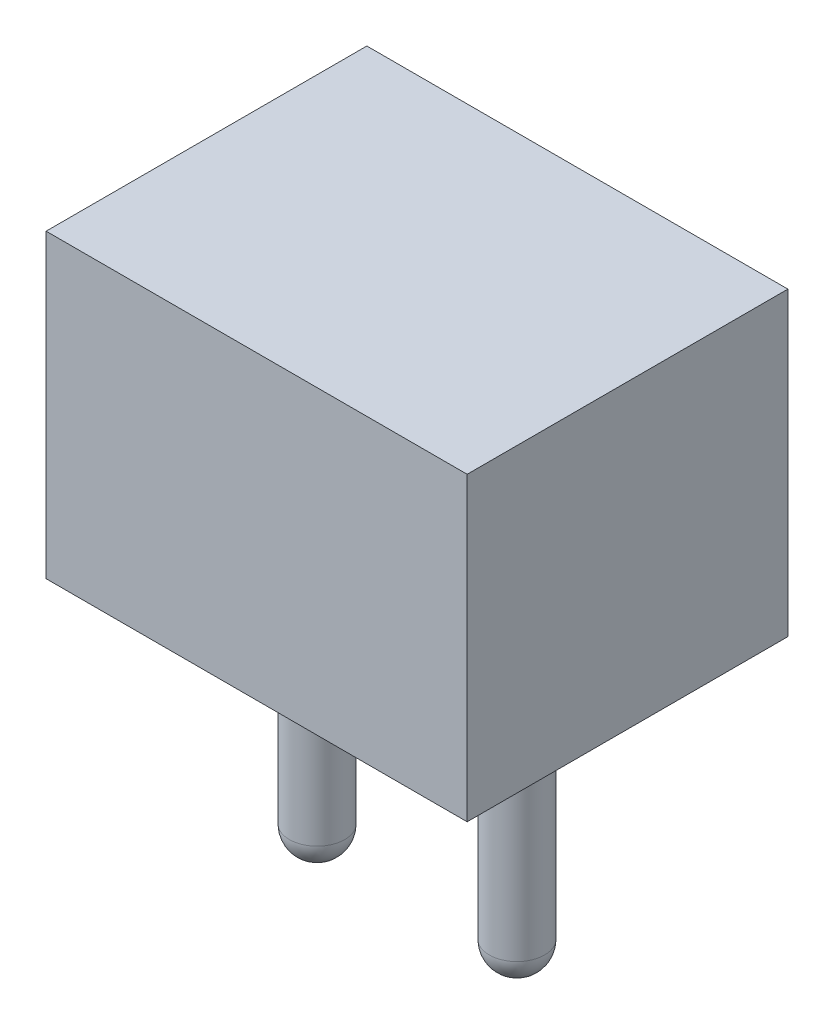
from build123d import *

# Parameters (mm, degrees)
SKETCH1_W           = 5.33
SKETCH1_H           = 4.06
BASE_EXTRUDE_DEPTH  = 3.81
SKETCH2_R           = 0.35
BOSS_EXTRUDE1_DEPTH = 3
DOME1_FACE_RADIUS   = 0.35
DOME1_HEIGHT        = 0.35
DOME2_FACE_RADIUS   = 0.35
DOME2_HEIGHT        = 0.35


with BuildPart() as part:
    # Sketch1 → Base-Extrude (new body)
    with BuildSketch(Plane(origin=(0, 0, 0), x_dir=(1, 0, 0), z_dir=(0, 1, 0))):
        with Locations((-1.265, 0)):
            Rectangle(SKETCH1_W, SKETCH1_H)
    extrude(amount=BASE_EXTRUDE_DEPTH)

    # Sketch2 → Boss-Extrude1 (add)
    with BuildSketch(Plane.XZ):
        Circle(SKETCH2_R)
        with Locations((-2.53, 0)):
            Circle(SKETCH2_R)
    extrude(amount=BOSS_EXTRUDE1_DEPTH)

    # Dome1: a dome of height H over a round flat face of radius A is a cap of a sphere of radius (A * A + H * H) / (2 * H)
    dome1_r = (DOME1_FACE_RADIUS * DOME1_FACE_RADIUS + DOME1_HEIGHT * DOME1_HEIGHT) / (2 * DOME1_HEIGHT)
    dome1_base = Plane((0, -3, 0), z_dir=(0, -1, 0))
    with Locations(dome1_base.offset(DOME1_HEIGHT - dome1_r)):
        dome1_ball = Sphere(dome1_r, mode=Mode.PRIVATE)
    add(split(dome1_ball, bisect_by=dome1_base, keep=Keep.TOP, mode=Mode.PRIVATE))

    # Dome2: a dome of height H over a round flat face of radius A is a cap of a sphere of radius (A * A + H * H) / (2 * H)
    dome2_r = (DOME2_FACE_RADIUS * DOME2_FACE_RADIUS + DOME2_HEIGHT * DOME2_HEIGHT) / (2 * DOME2_HEIGHT)
    dome2_base = Plane((-2.53, -3, 0), z_dir=(0, -1, 0))
    with Locations(dome2_base.offset(DOME2_HEIGHT - dome2_r)):
        dome2_ball = Sphere(dome2_r, mode=Mode.PRIVATE)
    add(split(dome2_ball, bisect_by=dome2_base, keep=Keep.TOP, mode=Mode.PRIVATE))


solid = part.part
